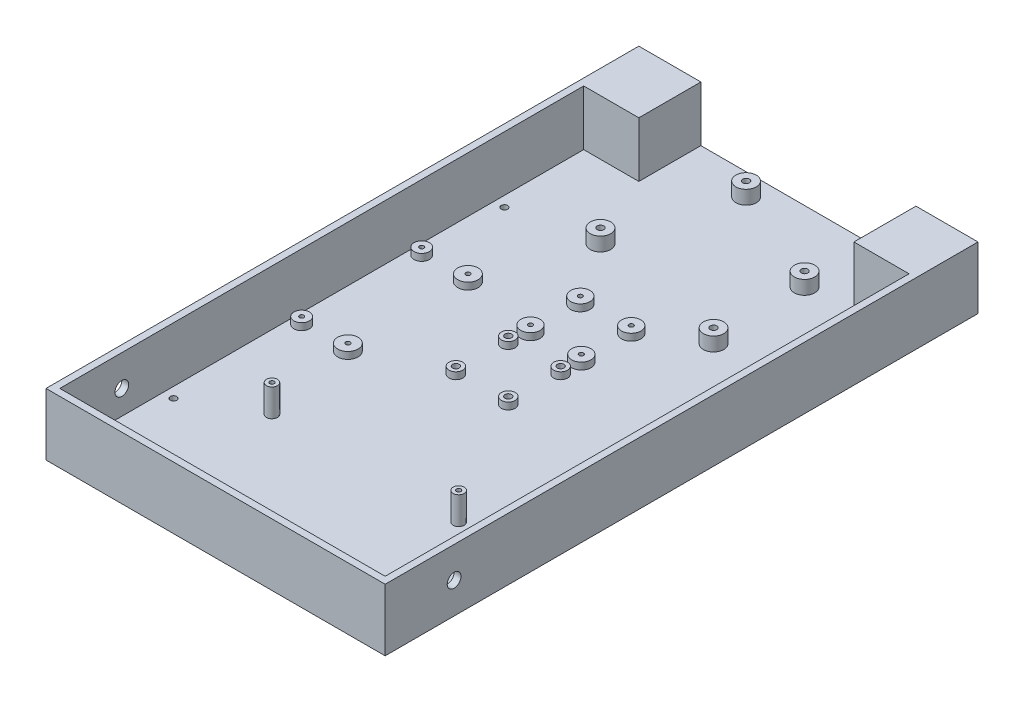
from build123d import *

# Parameters (mm, degrees)
SKETCH2_R           = 1.4986
BOSS_EXTRUDE3_DEPTH = 3.175
BOSS_EXTRUDE4_DEPTH = 25.4
SKETCH8_R           = 4.699
SKETCH8_R_2         = 1.524
BOSS_EXTRUDE5_DEPTH = 6.35
SKETCH8_3_R         = 1.524
CUT_EXTRUDE1_DEPTH  = 252.762622456
SKETCH10_R          = 3.556
SKETCH10_R_2        = 1.016
SKETCH10_R_3        = 4.699
SKETCH10_R_4        = 4.445
BOSS_EXTRUDE6_DEPTH = 3.175
SKETCH10_2_R        = 1.016
CUT_EXTRUDE2_DEPTH  = 252.762622456
SKETCH11_R          = 2.54
SKETCH11_R_2        = 1.016
BOSS_EXTRUDE7_DEPTH = 12.7
SKETCH11_2_R        = 1.016
CUT_EXTRUDE3_DEPTH  = 252.762622456
SKETCH12_W          = 25.4
SKETCH12_H          = 25.4
BOSS_EXTRUDE8_DEPTH = 25.4
SKETCH13_R          = 3.175
CUT_EXTRUDE4_DEPTH  = 282.967421343
SKETCH14_R          = 3.175
SKETCH14_R_2        = 1.524
BOSS_EXTRUDE9_DEPTH = 3.175
SKETCH16_R          = 1.524
CUT_EXTRUDE5_DEPTH  = 252.762622456


with BuildPart() as part:
    # Sketch2 → Boss-Extrude3 (new body)
    with BuildSketch(Plane(origin=(0, 0, 0), x_dir=(1, 0, 0), z_dir=(0, 1, 0))):
        Polygon((-61.101730223, 40.053150292), (88.758269777, 40.053150292), (91.933269777, 40.053150292), (91.933269777, -232.996849708), (88.758269777, -232.996849708), (-61.101730223, -232.996849708), (-64.276730223, -232.996849708), (-64.276730223, 40.053150292), align=None)
        with Locations((-56.339230223, -182.196849708)):
            Circle(SKETCH2_R, mode=Mode.SUBTRACT)
        with Locations((83.995769777, -182.196849708)):
            Circle(SKETCH2_R, mode=Mode.SUBTRACT)
        with Locations((-56.339230223, -29.796849708)):
            Circle(SKETCH2_R, mode=Mode.SUBTRACT)
        with Locations((83.995769777, -29.796849708)):
            Circle(SKETCH2_R, mode=Mode.SUBTRACT)
    extrude(amount=BOSS_EXTRUDE3_DEPTH)

    # Sketch7 → Boss-Extrude4 (add)
    with BuildSketch(Plane(origin=(0, 3.175, 0), x_dir=(1, 0, 0), z_dir=(0, 1, 0))):
        Polygon((-35.701730223, 40.053150292), (-64.276730223, 40.053150292), (-64.276730223, -232.996849708), (91.933269777, -232.996849708), (91.933269777, 40.053150292), (63.358269777, 40.053150292), (63.358269777, 36.878150292), (88.758269777, 36.878150292), (88.758269777, -229.821849708), (-61.101730223, -229.821849708), (-61.101730223, 36.878150292), (-35.701730223, 36.878150292), align=None)
    extrude(amount=BOSS_EXTRUDE4_DEPTH)

    # Sketch8 → Boss-Extrude5 (add)
    # profile 1 of 4: a face of its own
    with BuildSketch(Plane(origin=(0, 3.175, 0), x_dir=(1, 0, 0), z_dir=(0, 1, 0))):
        with Locations((-4.840730223, 30.020150292)):
            Circle(SKETCH8_R)
        with Locations((-4.840730223, 30.020150292)):
            Circle(SKETCH8_R_2, mode=Mode.SUBTRACT)
    # profile 2 of 4: a face of its own
    with BuildSketch(Plane(origin=(0, 3.175, 0), x_dir=(1, 0, 0), z_dir=(0, 1, 0))):
        with Locations((-19.699730223, -22.176849708)):
            Circle(SKETCH8_R)
        with Locations((-19.699730223, -22.176849708)):
            Circle(SKETCH8_R_2, mode=Mode.SUBTRACT)
    # profile 3 of 4: a face of its own
    with BuildSketch(Plane(origin=(0, 3.175, 0), x_dir=(1, 0, 0), z_dir=(0, 1, 0))):
        with Locations((44.562269777, 7.541150292)):
            Circle(SKETCH8_R)
        with Locations((44.562269777, 7.541150292)):
            Circle(SKETCH8_R_2, mode=Mode.SUBTRACT)
    # profile 4 of 4: a face of its own
    with BuildSketch(Plane(origin=(0, 3.175, 0), x_dir=(1, 0, 0), z_dir=(0, 1, 0))):
        with Locations((46.213269777, -36.019849708)):
            Circle(SKETCH8_R)
        with Locations((46.213269777, -36.019849708)):
            Circle(SKETCH8_R_2, mode=Mode.SUBTRACT)
    extrude(amount=BOSS_EXTRUDE5_DEPTH)

    # Sketch8_3 → Cut-Extrude1 (cut, through all)
    with BuildSketch(Plane(origin=(0, 3.175, 0), x_dir=(1, 0, 0), z_dir=(0, 1, 0))):
        with Locations((-4.840730223, 30.020150292)):
            Circle(SKETCH8_3_R)
        with Locations((-19.699730223, -22.176849708)):
            Circle(SKETCH8_3_R)
        with Locations((44.562269777, 7.541150292)):
            Circle(SKETCH8_3_R)
        with Locations((46.213269777, -36.019849708)):
            Circle(SKETCH8_3_R)
    extrude(amount=-CUT_EXTRUDE1_DEPTH, mode=Mode.SUBTRACT)

    # Sketch10 → Boss-Extrude6 (add)
    # profile 1 of 8: a face of its own
    with BuildSketch(Plane(origin=(0, 3.175, 0), x_dir=(1, 0, 0), z_dir=(0, 1, 0))):
        with Locations((-56.339230223, -67.896849708)):
            Circle(SKETCH10_R)
        with Locations((-56.339230223, -67.896849708)):
            Circle(SKETCH10_R_2, mode=Mode.SUBTRACT)
    # profile 2 of 8: a face of its own
    with BuildSketch(Plane(origin=(0, 3.175, 0), x_dir=(1, 0, 0), z_dir=(0, 1, 0))):
        with Locations((-35.041330223, -67.896849708)):
            Circle(SKETCH10_R_3)
        with Locations((-35.041330223, -67.896849708)):
            Circle(SKETCH10_R_2, mode=Mode.SUBTRACT)
    # profile 3 of 8: a face of its own
    with BuildSketch(Plane(origin=(0, 3.175, 0), x_dir=(1, 0, 0), z_dir=(0, 1, 0))):
        with Locations((-56.339230223, -123.192649708)):
            Circle(SKETCH10_R)
        with Locations((-56.339230223, -123.192649708)):
            Circle(SKETCH10_R_2, mode=Mode.SUBTRACT)
    # profile 4 of 8: a face of its own
    with BuildSketch(Plane(origin=(0, 3.175, 0), x_dir=(1, 0, 0), z_dir=(0, 1, 0))):
        with Locations((-35.041330223, -123.192649708)):
            Circle(SKETCH10_R_3)
        with Locations((-35.041330223, -123.192649708)):
            Circle(SKETCH10_R_2, mode=Mode.SUBTRACT)
    # profile 5 of 8: a face of its own
    with BuildSketch(Plane(origin=(0, 3.175, 0), x_dir=(1, 0, 0), z_dir=(0, 1, 0))):
        with Locations((-0.292403635, -50.864423121)):
            Circle(SKETCH10_R_4)
        with Locations((-0.292403635, -50.864423121)):
            Circle(SKETCH10_R_2, mode=Mode.SUBTRACT)
    # profile 6 of 8: a face of its own
    with BuildSketch(Plane(origin=(0, 3.175, 0), x_dir=(1, 0, 0), z_dir=(0, 1, 0))):
        with Locations((23.151796365, -50.864423121)):
            Circle(SKETCH10_R_4)
        with Locations((23.151796365, -50.864423121)):
            Circle(SKETCH10_R_2, mode=Mode.SUBTRACT)
    # profile 7 of 8: a face of its own
    with BuildSketch(Plane(origin=(0, 3.175, 0), x_dir=(1, 0, 0), z_dir=(0, 1, 0))):
        with Locations((23.151796365, -73.851423121)):
            Circle(SKETCH10_R_4)
        with Locations((23.151796365, -73.851423121)):
            Circle(SKETCH10_R_2, mode=Mode.SUBTRACT)
    # profile 8 of 8: a face of its own
    with BuildSketch(Plane(origin=(0, 3.175, 0), x_dir=(1, 0, 0), z_dir=(0, 1, 0))):
        with Locations((-0.292403635, -73.851423121)):
            Circle(SKETCH10_R_4)
        with Locations((-0.292403635, -73.851423121)):
            Circle(SKETCH10_R_2, mode=Mode.SUBTRACT)
    extrude(amount=BOSS_EXTRUDE6_DEPTH)

    # Sketch10_2 → Cut-Extrude2 (cut, through all)
    with BuildSketch(Plane(origin=(0, 3.175, 0), x_dir=(1, 0, 0), z_dir=(0, 1, 0))):
        with Locations((-56.339230223, -67.896849708)):
            Circle(SKETCH10_2_R)
        with Locations((-35.041330223, -67.896849708)):
            Circle(SKETCH10_2_R)
        with Locations((-35.041330223, -123.192649708)):
            Circle(SKETCH10_2_R)
        with Locations((-56.339230223, -123.192649708)):
            Circle(SKETCH10_2_R)
        with Locations((-0.292403635, -50.864423121)):
            Circle(SKETCH10_2_R)
        with Locations((23.151796365, -50.864423121)):
            Circle(SKETCH10_2_R)
        with Locations((-0.292403635, -73.851423121)):
            Circle(SKETCH10_2_R)
        with Locations((23.151796365, -73.851423121)):
            Circle(SKETCH10_2_R)
    extrude(amount=-CUT_EXTRUDE2_DEPTH, mode=Mode.SUBTRACT)

    # Sketch11 → Boss-Extrude7 (add)
    # profile 1 of 4: a face of its own
    with BuildSketch(Plane(origin=(0, 3.175, 0), x_dir=(1, 0, 0), z_dir=(0, 1, 0))):
        with Locations((-27.287980223, -223.802049708)):
            Circle(SKETCH11_R)
        with Locations((-27.287980223, -223.802049708)):
            Circle(SKETCH11_R_2, mode=Mode.SUBTRACT)
    # profile 2 of 4: a face of its own
    with BuildSketch(Plane(origin=(0, 3.175, 0), x_dir=(1, 0, 0), z_dir=(0, 1, 0))):
        with Locations((-27.311451073, -165.890049708)):
            Circle(SKETCH11_R)
        with Locations((-27.311451073, -165.890049708)):
            Circle(SKETCH11_R_2, mode=Mode.SUBTRACT)
    # profile 3 of 4: a face of its own
    with BuildSketch(Plane(origin=(0, 3.175, 0), x_dir=(1, 0, 0), z_dir=(0, 1, 0))):
        with Locations((58.691019777, -165.890049708)):
            Circle(SKETCH11_R)
        with Locations((58.691019777, -165.890049708)):
            Circle(SKETCH11_R_2, mode=Mode.SUBTRACT)
    # profile 4 of 4: a face of its own
    with BuildSketch(Plane(origin=(0, 3.175, 0), x_dir=(1, 0, 0), z_dir=(0, 1, 0))):
        with Locations((58.691019777, -223.802049708)):
            Circle(SKETCH11_R)
        with Locations((58.691019777, -223.802049708)):
            Circle(SKETCH11_R_2, mode=Mode.SUBTRACT)
    extrude(amount=BOSS_EXTRUDE7_DEPTH)

    # Sketch11_2 → Cut-Extrude3 (cut, through all)
    with BuildSketch(Plane(origin=(0, 3.175, 0), x_dir=(1, 0, 0), z_dir=(0, 1, 0))):
        with Locations((-27.287980223, -223.802049708)):
            Circle(SKETCH11_2_R)
        with Locations((-27.311451073, -165.890049708)):
            Circle(SKETCH11_2_R)
        with Locations((58.691019777, -165.890049708)):
            Circle(SKETCH11_2_R)
        with Locations((58.691019777, -223.802049708)):
            Circle(SKETCH11_2_R)
    extrude(amount=-CUT_EXTRUDE3_DEPTH, mode=Mode.SUBTRACT)

    # Sketch12 → Boss-Extrude8 (add)
    with BuildSketch(Plane(origin=(0, 3.175, 0), x_dir=(1, 0, 0), z_dir=(0, 1, 0))):
        with Locations((76.058269777, 24.178150292)):
            Rectangle(SKETCH12_W, SKETCH12_H)
        with Locations((-48.401730223, 24.178150292)):
            Rectangle(SKETCH12_W, SKETCH12_H)
    extrude(amount=BOSS_EXTRUDE8_DEPTH)

    # Sketch13 → Cut-Extrude4 (cut, through all)
    with BuildSketch(Plane.ZY.offset(64.276730223)):
        with Locations((201.246849708, 14.2875)):
            Circle(SKETCH13_R)
    extrude(amount=-CUT_EXTRUDE4_DEPTH, mode=Mode.SUBTRACT)

    # Sketch14 → Boss-Extrude9 (add)
    # profile 1 of 4: a face of its own
    with BuildSketch(Plane(origin=(0, 3.175, 0), x_dir=(1, 0, 0), z_dir=(0, 1, 0))):
        with Locations((-0.978203635, -83.376423121)):
            Circle(SKETCH14_R)
        with Locations((-0.978203635, -83.376423121)):
            Circle(SKETCH14_R_2, mode=Mode.SUBTRACT)
    # profile 2 of 4: a face of its own
    with BuildSketch(Plane(origin=(0, 3.175, 0), x_dir=(1, 0, 0), z_dir=(0, 1, 0))):
        with Locations((-0.978203635, -107.506423121)):
            Circle(SKETCH14_R)
        with Locations((-0.978203635, -107.506423121)):
            Circle(SKETCH14_R_2, mode=Mode.SUBTRACT)
    # profile 3 of 4: a face of its own
    with BuildSketch(Plane(origin=(0, 3.175, 0), x_dir=(1, 0, 0), z_dir=(0, 1, 0))):
        with Locations((23.151796365, -83.376423121)):
            Circle(SKETCH14_R)
        with Locations((23.151796365, -83.376423121)):
            Circle(SKETCH14_R_2, mode=Mode.SUBTRACT)
    # profile 4 of 4: a face of its own
    with BuildSketch(Plane(origin=(0, 3.175, 0), x_dir=(1, 0, 0), z_dir=(0, 1, 0))):
        with Locations((23.151796365, -107.506423121)):
            Circle(SKETCH14_R)
        with Locations((23.151796365, -107.506423121)):
            Circle(SKETCH14_R_2, mode=Mode.SUBTRACT)
    extrude(amount=BOSS_EXTRUDE9_DEPTH)

    # Sketch16 → Cut-Extrude5 (cut, through all)
    with BuildSketch(Plane(origin=(0, 3.175, 0), x_dir=(1, 0, 0), z_dir=(0, 1, 0))):
        with Locations((-0.978203635, -83.376423121)):
            Circle(SKETCH16_R)
        with Locations((23.151796365, -83.376423121)):
            Circle(SKETCH16_R)
        with Locations((23.151796365, -107.506423121)):
            Circle(SKETCH16_R)
        with Locations((-0.978203635, -107.506423121)):
            Circle(SKETCH16_R)
    extrude(amount=-CUT_EXTRUDE5_DEPTH, mode=Mode.SUBTRACT)


solid = part.part
